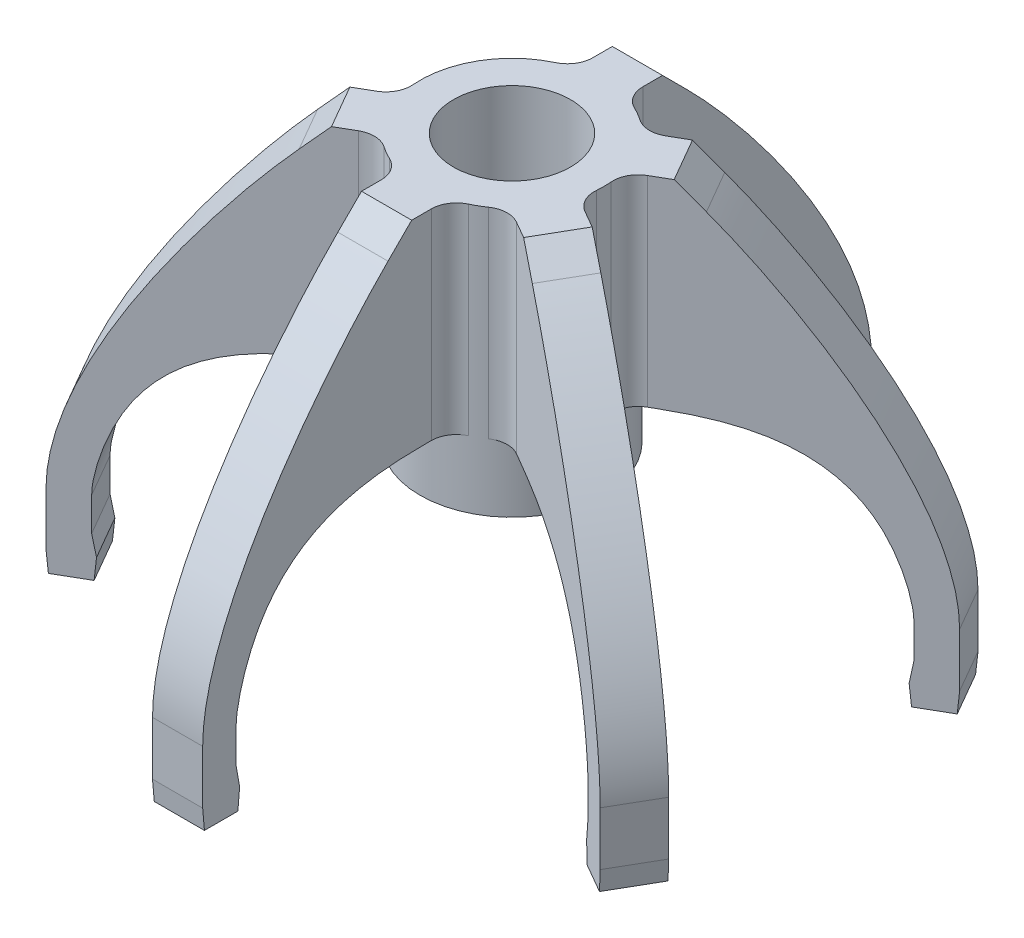
from build123d import *

# Parameters (mm, degrees)
SKETCH1_R           = 5.5
SKETCH1_R_2         = 1.25
BOSS_EXTRUDE1_DEPTH = 16
BOSS_EXTRUDE2_DEPTH = 1.5
BOSS_EXTRUDE3_DEPTH = 3
CIRPATTERN1_COUNT   = 5
CIRPATTERN1_ANGLE   = 240
FILLET1_R           = 1.5
SKETCH6_R           = 3.5
CUT_EXTRUDE1_DEPTH  = 15.2


with BuildPart() as part:
    # Sketch1 → Boss-Extrude1 (new body)
    with BuildSketch(Plane(origin=(0, 0, 0), x_dir=(1, 0, 0), z_dir=(0, 1, 0))):
        Circle(SKETCH1_R)
        Circle(SKETCH1_R_2, mode=Mode.SUBTRACT)
    extrude(amount=BOSS_EXTRUDE1_DEPTH)

    # Sketch2 → Boss-Extrude2 (add, symmetric)
    with BuildSketch(Plane(origin=(0, 0, 0), x_dir=(0, 0, -1), z_dir=(1, 0, 0))):
        with BuildLine():
            Line((18, -5), (20, -5))
            add(Edge.make_bspline(
                [(8.914213562, 14.585786438), (13.074333826, 10.425666174), (20, 1.461761402), (20, -5)],
                knots=[0.14734609, 0.14734609, 0.14734609, 0.14734609, 1, 1, 1, 1], degree=3))
            Line((8.914213562, 14.585786438), (7.5, 16))
            Line((7.5, 16), (5.5, 16))
            Line((5.5, 16), (1.25, 16))
            Line((1.25, 16), (1.25, 4))
            Line((1.25, 4), (6.70571865, 4))
            add(Edge.make_bspline(
                [(6.70571865, 4), (10.522194615, 4), (16.021169224, 3.257262603), (18, -4.005650027), (18, -5)],
                knots=[0, 0, 0, 0, 0.785490543, 1, 1, 1, 1], degree=3))
        make_face()
    boss_extrude2 = extrude(amount=BOSS_EXTRUDE2_DEPTH, both=True)

    # Sketch8 → Boss-Extrude3 (add)
    with BuildSketch(Plane(origin=(1.5, 0, 0), x_dir=(0, 0, -1), z_dir=(1, 0, 0))):
        Polygon((18, -7), (17.788407623, -8.2), (17.894203812, -9.409255967), (19.894203812, -9.409255967), (20, -8.2), (20, -7), (20, -5), (18, -5), align=None)
    boss_extrude3 = extrude(amount=-BOSS_EXTRUDE3_DEPTH)

    # CirPattern1: Boss-Extrude2, Boss-Extrude3 ×5 about axis
    cirpattern1_axis = Axis((0, 16, 0), (0, -1, 0))
    for i in range(1, CIRPATTERN1_COUNT):
        add(boss_extrude2.rotate(cirpattern1_axis, i * CIRPATTERN1_ANGLE / (CIRPATTERN1_COUNT - 1)))
        add(boss_extrude3.rotate(cirpattern1_axis, i * CIRPATTERN1_ANGLE / (CIRPATTERN1_COUNT - 1)))

    # Fillet1
    fillet1_edges = [part.edges().sort_by_distance(p)[0] for p in [
        (-5.332575695, 10, 1.346713205),
        (1.5, 10, -5.291502622),
        (-1.5, 10, -5.291502622),
        (3.832575695, 10, -3.944789417),
        (5.332575695, 10, 1.346713205),
        (1.5, 10, 5.291502622),
        (-3.832575695, 10, 3.944789417),
        (5.332575695, 10, -1.346713205),
        (3.832575695, 10, 3.944789417),
        (-1.5, 10, 5.291502622),
    ]]
    fillet(fillet1_edges, radius=FILLET1_R)

    # Sketch6 → Cut-Extrude1 (cut)
    with BuildSketch(Plane(origin=(0, 16, 0), x_dir=(1, 0, 0), z_dir=(0, 1, 0))):
        Circle(SKETCH6_R)
    extrude(amount=-CUT_EXTRUDE1_DEPTH, mode=Mode.SUBTRACT)


solid = part.part
